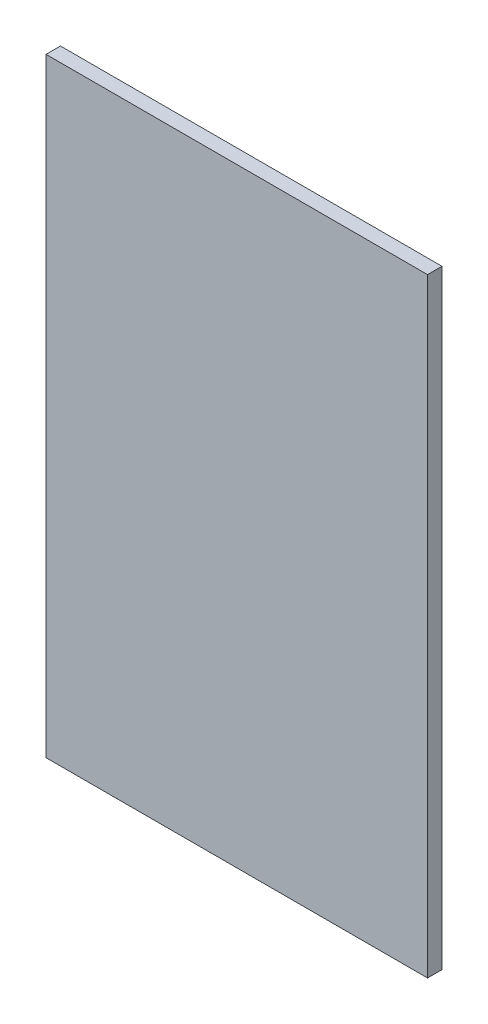
from build123d import *

# Parameters (mm, degrees)
SKETCH1_W           = 476
SKETCH1_H           = 760
BOSS_EXTRUDE1_DEPTH = 18


with BuildPart() as part:
    # Sketch1 → Boss-Extrude1 (new body)
    with BuildSketch(Plane.XY):
        Rectangle(SKETCH1_W, SKETCH1_H)
    extrude(amount=BOSS_EXTRUDE1_DEPTH)


solid = part.part
